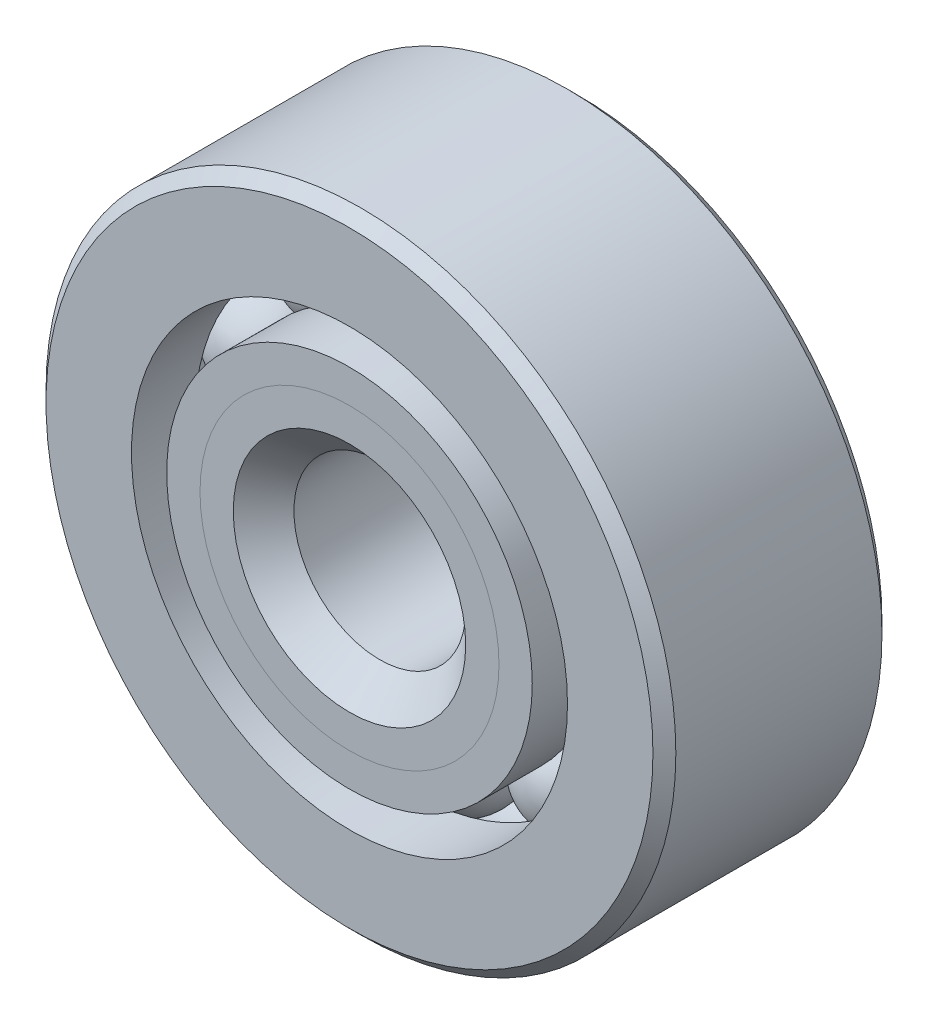
from build123d import *

# Parameters (mm, degrees)
CIRPATTERN1_COUNT = 10


with BuildPart() as part:
    # Sketch1 → Revolve1 (revolve)
    with BuildSketch(Plane(origin=(0, 0, 0), x_dir=(0, 0, -1), z_dir=(1, 0, 0))):
        with BuildLine():
            Line((2.8575, 8.73125), (-2.8575, 8.73125))
            Line((-2.8575, 8.73125), (-3.175, 8.41375))
            Line((-3.175, 8.41375), (-3.175, 6.044711538))
            Line((-3.175, 6.044711538), (-1.411111111, 6.044711538))
            ThreePointArc((-1.411111111, 6.044711538), (0, 7.049511277), (1.411111111, 6.044711538))
            Line((1.411111111, 6.044711538), (3.175, 6.044711538))
            Line((3.175, 6.044711538), (3.175, 8.41375))
            Line((3.175, 8.41375), (2.8575, 8.73125))
        make_face()
    revolve(axis=Axis((0, 0, 3.175), (0, 0, -1)))


with BuildPart() as body_2:
    # Sketch2 → Revolve2 (revolve)
    with BuildSketch(Plane(origin=(0, 0, 0), x_dir=(0, 0, -1), z_dir=(1, 0, 0))):
        with BuildLine():
            Line((-3.175, 5.067788462), (-1.411111111, 5.067788462))
            ThreePointArc((-1.411111111, 5.067788462), (-0.866149104, 4.33985575), (0, 4.062988723))
            Line((0, 4.062988723), (0, 3.222119361))
            Line((0, 3.222119361), (-2.25216545, 3.222119361))
            Line((-2.25216545, 3.222119361), (-3.175, 4.144953911))
            Line((-3.175, 4.144953911), (-3.175, 5.067788462))
        make_face()
    revolve(axis=Axis((0, 0, 3.175), (0, 0, -1)))


with BuildPart() as body_3:
    # Sketch3 → Revolve3 (revolve)
    with BuildSketch(Plane(origin=(0, 0, 0), x_dir=(0, 0, -1), z_dir=(1, 0, 0))):
        with BuildLine():
            Line((-3.175, 4.144953911), (-2.25216545, 3.222119361))
            Line((-2.25216545, 3.222119361), (0, 3.222119361))
            Line((0, 3.222119361), (0, 4.062988723))
            ThreePointArc((0, 4.062988723), (0.866149104, 4.33985575), (1.411111111, 5.067788462))
            Line((1.411111111, 5.067788462), (3.175, 5.067788462))
            Line((3.175, 5.067788462), (3.175, 2.69875))
            Line((3.175, 2.69875), (2.8575, 2.38125))
            Line((2.8575, 2.38125), (-2.334130639, 2.38125))
            Line((-2.334130639, 2.38125), (-3.175, 3.222119361))
            Line((-3.175, 3.222119361), (-3.175, 4.144953911))
        make_face()
    revolve(axis=Axis((0, 0, 3.175), (0, 0, -1)))


with BuildPart() as body_4:
    # Sketch4 → Revolve4 (revolve)
    with BuildSketch(Plane(origin=(0, 0, 0), x_dir=(0, 0, -1), z_dir=(1, 0, 0))):
        with BuildLine():
            Line((-1.493261277, 5.55625), (1.493261277, 5.55625))
            ThreePointArc((1.493261277, 5.55625), (0, 7.049511277), (-1.493261277, 5.55625))
        make_face()
    revolve(axis=Axis((0, 5.55625, 1.493261277), (0, 0, -1)))


with BuildPart() as cirpattern1_1:
    # CirPattern1: pattern copy
    add(body_4.part.rotate(Axis((0, 0, -3.175), (0, 0, 1)), 1 * 360 / CIRPATTERN1_COUNT))


with BuildPart() as cirpattern1_2:
    # CirPattern1: pattern copy
    add(body_4.part.rotate(Axis((0, 0, -3.175), (0, 0, 1)), 2 * 360 / CIRPATTERN1_COUNT))


with BuildPart() as cirpattern1_3:
    # CirPattern1: pattern copy
    add(body_4.part.rotate(Axis((0, 0, -3.175), (0, 0, 1)), 3 * 360 / CIRPATTERN1_COUNT))


with BuildPart() as cirpattern1_4:
    # CirPattern1: pattern copy
    add(body_4.part.rotate(Axis((0, 0, -3.175), (0, 0, 1)), 4 * 360 / CIRPATTERN1_COUNT))


with BuildPart() as cirpattern1_5:
    # CirPattern1: pattern copy
    add(body_4.part.rotate(Axis((0, 0, -3.175), (0, 0, 1)), 5 * 360 / CIRPATTERN1_COUNT))


with BuildPart() as cirpattern1_6:
    # CirPattern1: pattern copy
    add(body_4.part.rotate(Axis((0, 0, -3.175), (0, 0, 1)), 6 * 360 / CIRPATTERN1_COUNT))


with BuildPart() as cirpattern1_7:
    # CirPattern1: pattern copy
    add(body_4.part.rotate(Axis((0, 0, -3.175), (0, 0, 1)), 7 * 360 / CIRPATTERN1_COUNT))


with BuildPart() as cirpattern1_8:
    # CirPattern1: pattern copy
    add(body_4.part.rotate(Axis((0, 0, -3.175), (0, 0, 1)), 8 * 360 / CIRPATTERN1_COUNT))


with BuildPart() as cirpattern1_9:
    # CirPattern1: pattern copy
    add(body_4.part.rotate(Axis((0, 0, -3.175), (0, 0, 1)), 9 * 360 / CIRPATTERN1_COUNT))


solid = Compound([part.part, body_2.part, body_3.part, body_4.part, cirpattern1_1.part, cirpattern1_2.part, cirpattern1_3.part, cirpattern1_4.part, cirpattern1_5.part, cirpattern1_6.part, cirpattern1_7.part, cirpattern1_8.part, cirpattern1_9.part])
